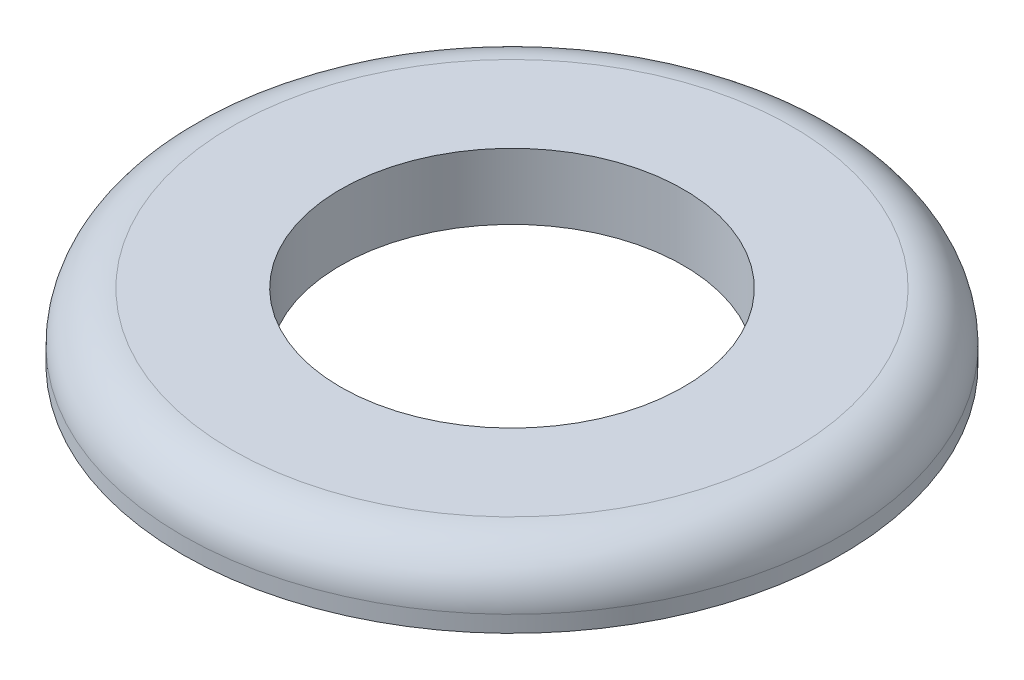
from build123d import *

# Parameters (mm, degrees)
SKETCH1_R           = 5
SKETCH1_R_2         = 2.6
BOSS_EXTRUDE1_DEPTH = 1
FILLET1_R           = 0.75


with BuildPart() as part:
    # Sketch1 → Boss-Extrude1 (new body)
    with BuildSketch(Plane(origin=(0, 0, 0), x_dir=(1, 0, 0), z_dir=(0, 1, 0))):
        Circle(SKETCH1_R)
        Circle(SKETCH1_R_2, mode=Mode.SUBTRACT)
    extrude(amount=BOSS_EXTRUDE1_DEPTH)

    # Fillet1
    fillet1_edges = [part.edges().sort_by_distance(p)[0] for p in [
        (-5, 1, 0),
    ]]
    fillet(fillet1_edges, radius=FILLET1_R)


solid = part.part
